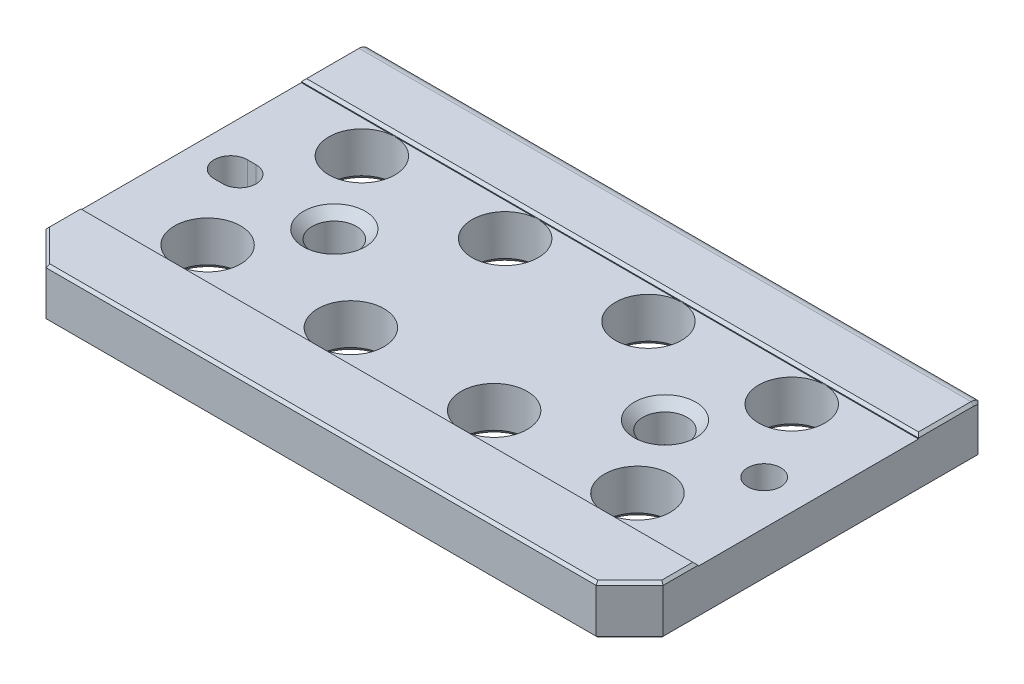
from build123d import *

# Parameters (mm, degrees)
EXTRUDE1_DEPTH                         = 88.9
EXTRUDE5_REACH                         = 90.9
EXTRUDE5_DIRECTION_2_REACH             = 90.9
F_3_4_0_75_DIAMETER_HOLE1_D            = 19.05
F_3_4_0_75_DIAMETER_HOLE1_DEPTH        = 18.5166
SKETCH6_W                              = 177.8
SKETCH6_H                              = 63.5
EXTRUDE2_DEPTH                         = 1.016
CHAMFER10_SIZE                         = 9.652
SKETCH35_W                             = 101.092
SKETCH35_H                             = 4.2926
EXTRUDE11_DEPTH                        = 89.9
EXTRUDE11_DEPTH_BACK                   = 89.9
F_3_8_0_375_DIAMETER_HOLE1_D           = 9.54278
F_3_8_0_375_DIAMETER_HOLE1_CSINK_D     = 14.224
F_3_8_0_375_DIAMETER_HOLE1_CSINK_ANGLE = 90
EXTRUDE8_DEPTH                         = 15.224
CHAMFER13_SIZE                         = 2.286
F_1_2_0_5_DIAMETER_HOLE4_AT_2_COUNT    = 2
F_1_2_0_5_DIAMETER_HOLE4_AT_2_PITCH    = 95.25
CHAMFER16_SIZE                         = 0.762
CHAMFER19_SIZE                         = 1.524


with BuildPart() as part:
    # Sketch1 → Extrude1 (new body, symmetric)
    with BuildSketch(Plane(origin=(0, 0, 0), x_dir=(0, 0, -1), z_dir=(1, 0, 0))):
        Polygon((-47.625, 0), (-51.435, 0), (-51.435, -18.5166), (-47.625, -18.5166), (47.625, -18.5166), (47.625, 0), align=None)
    extrude(amount=EXTRUDE1_DEPTH, both=True)

    # Extrude5: up to this face of the body (flat: up to its plane)
    extrude5_end = Plane(part.part.faces().sort_by_distance((-88.9, -9.2583, 1.905))[0])
    # Sketch10 → Extrude5 (add, up to the picked face)
    with BuildSketch(Plane(origin=(0, 0, 0), x_dir=(0, 0, -1), z_dir=(1, 0, 0)), mode=Mode.PRIVATE) as extrude5_sk1:
        with BuildLine():
            Line((47.625, 0), (47.625, -18.5166))
            Line((47.625, -18.5166), (49.657, -18.5166))
            Line((49.657, -18.5166), (49.657, -0.735409666))
            ThreePointArc((49.657, -0.735409666), (48.705491945, -0.189508055), (47.625, 0))
        make_face()
    extrude5_tool1 = split(extrude(extrude5_sk1.sketch, amount=-EXTRUDE5_REACH, mode=Mode.PRIVATE), bisect_by=extrude5_end, keep=Keep.BOTH, mode=Mode.PRIVATE)
    add(extrude5_tool1.solids().sort_by(Axis((0, -9.373301, -48.63438), (-1, 0, 0)))[0])

    # Extrude5 direction 2: up to this face of the body (flat: up to its plane)
    extrude5_direction_2_end = Plane(part.part.faces().sort_by_distance((88.9, -9.2583, 1.905))[0])
    # Sketch10 → Extrude5 direction 2 (add, up to the picked face)
    with BuildSketch(Plane(origin=(0, 0, 0), x_dir=(0, 0, -1), z_dir=(1, 0, 0)), mode=Mode.PRIVATE) as extrude5_direction_2_sk1:
        with BuildLine():
            Line((47.625, 0), (47.625, -18.5166))
            Line((47.625, -18.5166), (49.657, -18.5166))
            Line((49.657, -18.5166), (49.657, -0.735409666))
            ThreePointArc((49.657, -0.735409666), (48.705491945, -0.189508055), (47.625, 0))
        make_face()
    extrude5_direction_2_tool1 = split(extrude(extrude5_direction_2_sk1.sketch, amount=EXTRUDE5_DIRECTION_2_REACH, mode=Mode.PRIVATE), bisect_by=extrude5_direction_2_end, keep=Keep.BOTH, mode=Mode.PRIVATE)
    add(extrude5_direction_2_tool1.solids().sort_by(Axis((0, -9.373301, -48.63438), (1, 0, 0)))[0])

    # 3/4 (0.75) Diameter Hole1
    with Locations(Plane(origin=(100.583096031, 0, 72.51255066), x_dir=(-1, 0, 0), z_dir=(0, 1, 0))):
        with Locations((162.495596031, -94.73755066), (121.220596031, -94.73755066), (79.945596031, -94.73755066), (38.670596031, -94.73755066), (79.945596031, -50.28755066), (121.220596031, -50.28755066), (162.495596031, -50.28755066), (38.670596031, -50.28755066)):
            Hole(F_3_4_0_75_DIAMETER_HOLE1_D / 2, depth=F_3_4_0_75_DIAMETER_HOLE1_DEPTH)

    # Sketch6 → Extrude2 (cut)
    with BuildSketch(Plane(origin=(0, 0, 0), x_dir=(1, 0, 0), z_dir=(0, 1, 0))):
        Rectangle(SKETCH6_W, SKETCH6_H)
    extrude(amount=-EXTRUDE2_DEPTH, mode=Mode.SUBTRACT)

    # Chamfer10
    chamfer10_edges = [part.edges().sort_by_distance(p)[0] for p in [
        (88.9, -9.2583, 51.435),
        (-88.9, -9.2583, 51.435),
    ]]
    chamfer(chamfer10_edges, length=CHAMFER10_SIZE)

    # Sketch35 → Extrude11 (cut, two sides)
    with BuildSketch(Plane(origin=(0, 0, 0), x_dir=(0, 0, -1), z_dir=(1, 0, 0))) as extrude11_sk:
        with Locations((-0.889, -16.3703)):
            Rectangle(SKETCH35_W, SKETCH35_H)
    extrude(amount=EXTRUDE11_DEPTH, mode=Mode.SUBTRACT)
    extrude(extrude11_sk.sketch, amount=-EXTRUDE11_DEPTH_BACK, mode=Mode.SUBTRACT)

    # 3/8 (0.375) Diameter Hole1 (through all)
    with Locations(Plane(origin=(11.630068396, -14.224, 20.686230534), x_dir=(1, 0, 0), z_dir=(0, -1, 0))):
        with Locations((64.569931604, -20.686230534)):
            CounterSinkHole(F_3_8_0_375_DIAMETER_HOLE1_D / 2, F_3_8_0_375_DIAMETER_HOLE1_CSINK_D / 2, counter_sink_angle=F_3_8_0_375_DIAMETER_HOLE1_CSINK_ANGLE)

    # Sketch19 → Extrude8 (cut, through all)
    with BuildSketch(Plane.XZ.offset(14.224)):
        with BuildLine():
            Line((-77.47, 4.77139), (-74.93, 4.77139))
            ThreePointArc((-74.93, 4.77139), (-70.15861, 0), (-74.93, -4.77139))
            Line((-74.93, -4.77139), (-77.47, -4.77139))
            ThreePointArc((-77.47, -4.77139), (-82.24139, 0), (-77.47, 4.77139))
        make_face()
    extrude(amount=-EXTRUDE8_DEPTH, mode=Mode.SUBTRACT)

    # Chamfer13
    chamfer13_edges = [part.edges().sort_by_distance(p)[0] for p in [
        (-82.24139, -14.224, 0),
        (-76.2, -14.224, -4.77139),
        (-70.15861, -14.224, 0),
        (-76.2, -14.224, 4.77139),
    ]]
    chamfer(chamfer13_edges, length=CHAMFER13_SIZE)

    # Sketch26 → 1/2 (0.5) Diameter Hole4 (revolve, cut)
    with BuildSketch(Plane(origin=(-47.625, -1.016, 0), x_dir=(0, 0, 1), z_dir=(1, 0, 0))):
        Polygon((0, 0), (0, 13.208), (8.89, 13.208), (6.3754, 10.6934), (6.3754, 2.5146), (8.89, 0), align=None)
    f_1_2_0_5_diameter_hole4 = revolve(axis=Axis((-47.625, 5.334, 0), (0, -1, 0)), mode=Mode.SUBTRACT)

    # 1/2 (0.5) Diameter Hole4 at 2: 1/2 (0.5) Diameter Hole4 ×2
    with Locations(*[(i * F_1_2_0_5_DIAMETER_HOLE4_AT_2_PITCH, 0, 0) for i in range(1, F_1_2_0_5_DIAMETER_HOLE4_AT_2_COUNT)]):
        add(f_1_2_0_5_diameter_hole4, mode=Mode.SUBTRACT)

    # Chamfer16
    chamfer16_edges = [part.edges().sort_by_distance(p)[0] for p in [
        (0, 0, 31.75),
        (0, 0, -31.75),
        (88.9, 0, -39.6875),
        (0, 0, 51.435),
        (-84.074, 0, 46.609),
        (84.074, 0, 46.609),
        (-84.074, -14.224, 46.609),
        (88.9, -7.479704833, -49.657),
        (-88.9, -14.224, -3.937),
        (0, -14.224, 51.435),
        (84.074, -14.224, 46.609),
        (0, -14.224, -49.657),
        (88.9, -14.224, -3.937),
        (-88.9, -7.479704833, -49.657),
        (-88.9, -0.189508055, -48.705491945),
        (88.9, -0.189508055, -48.705491945),
        (-88.9, 0, -39.6875),
        (-88.9, 0, 36.7665),
        (88.9, 0, 36.7665),
    ]]
    chamfer(chamfer16_edges, length=CHAMFER16_SIZE)

    # Chamfer19
    chamfer19_edges = [part.edges().sort_by_distance(p)[0] for p in [
        (-71.4375, -14.224, 22.225),
        (11.1125, -14.224, 22.225),
        (11.1125, -14.224, -22.225),
        (-71.4375, -14.224, -22.225),
        (-30.1625, -14.224, -22.225),
        (52.3875, -14.224, -22.225),
        (-30.1625, -14.224, 22.225),
        (52.3875, -14.224, 22.225),
    ]]
    chamfer(chamfer19_edges, length=CHAMFER19_SIZE)


solid = part.part
